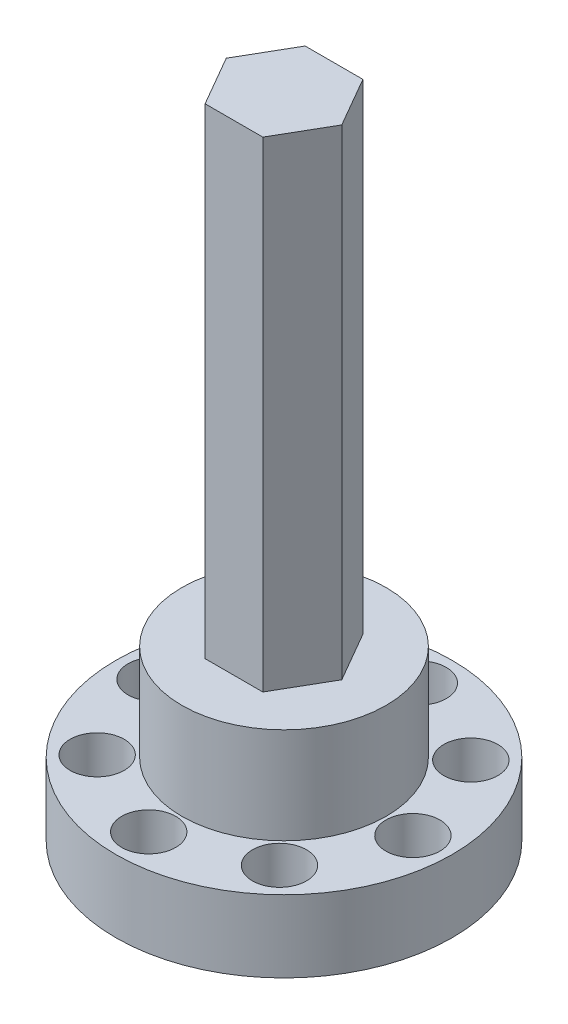
from build123d import *

# Parameters (mm, degrees)
BOSS_EXTRUDE1_DEPTH = 40
SKETCH3_R           = 8.5
BOSS_EXTRUDE2_DEPTH = 8
SKETCH4_R           = 14
BOSS_EXTRUDE3_DEPTH = 6
SKETCH13_R          = 1.25
CUT_EXTRUDE8_DEPTH  = 3
SKETCH14_R          = 5.25
CUT_EXTRUDE9_DEPTH  = 6
SKETCH15_R          = 2.25
CUT_EXTRUDE10_DEPTH = 4.5


with BuildPart() as part:
    # Sketch1 → Boss-Extrude1 (new body)
    with BuildSketch(Plane(origin=(0, 0, 0), x_dir=(1, 0, 0), z_dir=(0, 1, 0))):
        Polygon((-4.807996979, 0), (-2.40399849, -4.163847525), (2.40399849, -4.163847525), (4.807996979, 0), (2.40399849, 4.163847525), (-2.40399849, 4.163847525), align=None)
    extrude(amount=BOSS_EXTRUDE1_DEPTH)

    # Sketch3 → Boss-Extrude2 (add)
    with BuildSketch(Plane(origin=(0, 0, 0), x_dir=(-1, 0, 0), z_dir=(0, -1, 0))):
        Circle(SKETCH3_R)
    extrude(amount=BOSS_EXTRUDE2_DEPTH)

    # Sketch4 → Boss-Extrude3 (add)
    with BuildSketch(Plane(origin=(0, -8, 0), x_dir=(-1, 0, 0), z_dir=(0, -1, 0))):
        Circle(SKETCH4_R)
    extrude(amount=BOSS_EXTRUDE3_DEPTH)

    # Sketch13 → Cut-Extrude8 (cut)
    with BuildSketch(Plane(origin=(0, -14, 0), x_dir=(-1, 0, 0), z_dir=(0, -1, 0))):
        with Locations((7.588295109, 7.963527946)):
            Circle(SKETCH13_R)
        with Locations((10.996799542, 0.265329684)):
            Circle(SKETCH13_R)
        with Locations((7.963527946, -7.588295109)):
            Circle(SKETCH13_R)
        with Locations((0.265329684, -10.996799542)):
            Circle(SKETCH13_R)
        with Locations((-7.588295109, -7.963527946)):
            Circle(SKETCH13_R)
        with Locations((-10.996799542, -0.265329684)):
            Circle(SKETCH13_R)
        with Locations((-7.963527946, 7.588295109)):
            Circle(SKETCH13_R)
        with Locations((-0.265329684, 10.996799542)):
            Circle(SKETCH13_R)
    extrude(amount=-CUT_EXTRUDE8_DEPTH, mode=Mode.SUBTRACT)

    # Sketch14 → Cut-Extrude9 (cut)
    with BuildSketch(Plane(origin=(0, -14, 0), x_dir=(-1, 0, 0), z_dir=(0, -1, 0))):
        Circle(SKETCH14_R)
    extrude(amount=-CUT_EXTRUDE9_DEPTH, mode=Mode.SUBTRACT)

    # Sketch15 → Cut-Extrude10 (cut)
    with BuildSketch(Plane(origin=(0, -8, 0), x_dir=(1, 0, 0), z_dir=(0, 1, 0))):
        with Locations((10.996799542, -0.265329684)):
            Circle(SKETCH15_R)
        with Locations((7.588295109, -7.963527946)):
            Circle(SKETCH15_R)
        with Locations((-0.265329684, -10.996799542)):
            Circle(SKETCH15_R)
        with Locations((-7.963527946, -7.588295109)):
            Circle(SKETCH15_R)
        with Locations((-10.996799542, 0.265329684)):
            Circle(SKETCH15_R)
        with Locations((-7.588295109, 7.963527946)):
            Circle(SKETCH15_R)
        with Locations((0.265329684, 10.996799542)):
            Circle(SKETCH15_R)
        with Locations((7.963527946, 7.588295109)):
            Circle(SKETCH15_R)
    extrude(amount=-CUT_EXTRUDE10_DEPTH, mode=Mode.SUBTRACT)


solid = part.part
